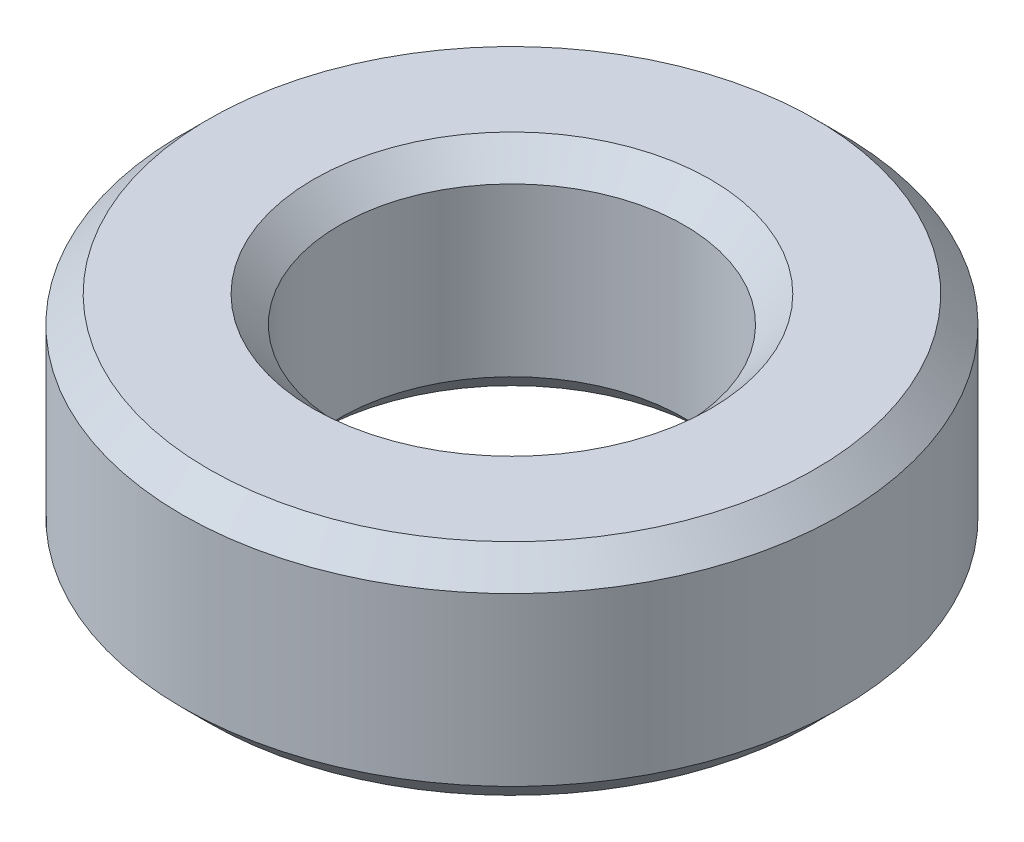
from build123d import *

# Parameters (mm, degrees)
SKETCH1_R           = 4.7625
SKETCH1_R_2         = 2.4892
BOSS_EXTRUDE1_DEPTH = 1.5875
CHAMFER1_SIZE       = 0.381


with BuildPart() as part:
    # Sketch1 → Boss-Extrude1 (new body, symmetric)
    with BuildSketch(Plane(origin=(0, 0, 0), x_dir=(1, 0, 0), z_dir=(0, 1, 0))):
        Circle(SKETCH1_R)
        Circle(SKETCH1_R_2, mode=Mode.SUBTRACT)
    extrude(amount=BOSS_EXTRUDE1_DEPTH, both=True)

    # Chamfer1
    chamfer1_edges = [part.edges().sort_by_distance(p)[0] for p in [
        (-4.7625, -1.5875, 0),
        (-4.7625, 1.5875, 0),
        (-2.4892, -1.5875, 0),
        (-2.4892, 1.5875, 0),
    ]]
    chamfer(chamfer1_edges, length=CHAMFER1_SIZE)


solid = part.part
